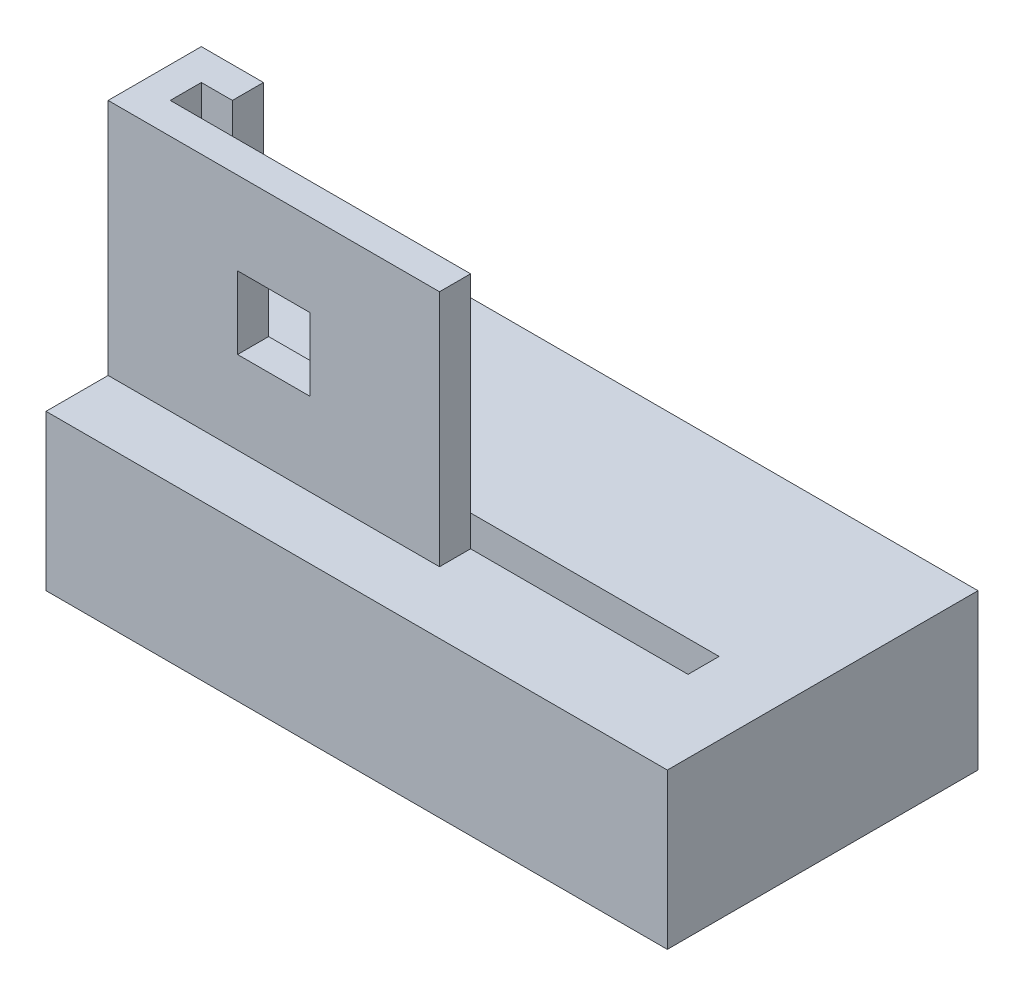
from build123d import *

# Parameters (mm, degrees)
ESQUISSE5_W             = 60
ESQUISSE5_H             = 30
BOSS_EXTRU_2_DEPTH      = 15
ESQUISSE6_R             = 5
BOSS_EXTRU_3_DEPTH      = 6
BOSS_EXTRU_4_DEPTH      = 23
ESQUISSE8_W             = 50
ESQUISSE8_H             = 3
ENL_V_MAT_EXTRU_1_DEPTH = 7
ESQUISSE9_W             = 7
ESQUISSE9_H             = 7
ENL_V_MAT_EXTRU_2_DEPTH = 7


with BuildPart() as part:
    # Esquisse5 → Boss.-Extru.2 (new body)
    with BuildSketch(Plane(origin=(0, 0, 0), x_dir=(1, 0, 0), z_dir=(0, 1, 0))):
        with Locations((-30, -15)):
            Rectangle(ESQUISSE5_W, ESQUISSE5_H)
    extrude(amount=BOSS_EXTRU_2_DEPTH)

    # Esquisse6 → Boss.-Extru.3 (add)
    with BuildSketch(Plane.XZ):
        with Locations((-55, 15)):
            Circle(ESQUISSE6_R)
        with Locations((-15, 15)):
            Circle(ESQUISSE6_R)
    extrude(amount=BOSS_EXTRU_3_DEPTH)

    # Esquisse7 → Boss.-Extru.4 (add)
    with BuildSketch(Plane(origin=(0, 15, 0), x_dir=(1, 0, 0), z_dir=(0, 1, 0))):
        Polygon((-60, -15), (-54, -15), (-54, -18), (-57, -18), (-57, -21), (-28, -21), (-28, -24), (-60, -24), align=None)
    extrude(amount=BOSS_EXTRU_4_DEPTH)

    # Esquisse8 → Enlèv. mat.-Extru.1 (cut)
    with BuildSketch(Plane(origin=(0, 15, 0), x_dir=(1, 0, 0), z_dir=(0, 1, 0))):
        with Locations((-32, -19.5)):
            Rectangle(ESQUISSE8_W, ESQUISSE8_H)
    extrude(amount=-ENL_V_MAT_EXTRU_1_DEPTH, mode=Mode.SUBTRACT)

    # Esquisse9 → Enlèv. mat.-Extru.2 (cut)
    with BuildSketch(Plane.XY.offset(24)):
        with Locations((-44, 26.5)):
            Rectangle(ESQUISSE9_W, ESQUISSE9_H)
    extrude(amount=-ENL_V_MAT_EXTRU_2_DEPTH, mode=Mode.SUBTRACT)


solid = part.part
